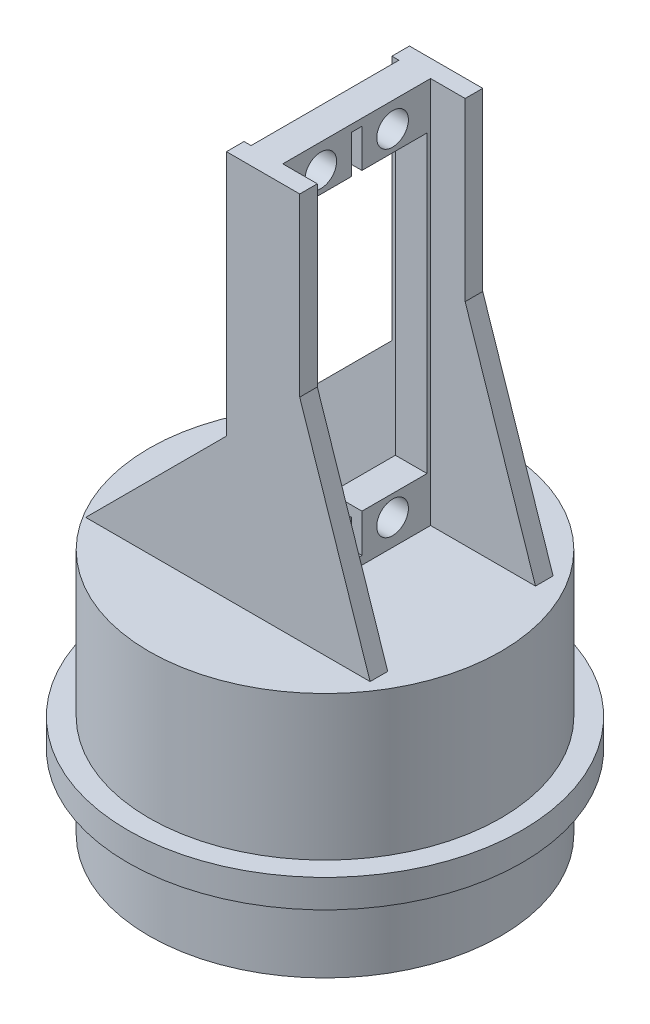
from build123d import *

# Parameters (mm, degrees)
SKETCH1_W           = 3
SKETCH1_H           = 4
SKETCH1_W_2         = 25
SKETCH1_H_2         = 35
SKETCH2_W           = 4.909608088
SKETCH2_H           = 2.5
SKETCH2_W_2         = 1
BOSS_EXTRUDE1_DEPTH = 55
CHAMFER1_SIZE       = 10
CHAMFER1_SIZE2      = 30
CHAMFER2_SIZE       = 20
SKETCH3_R           = 2.25
SKETCH3_W           = 20
SKETCH3_H           = 41.913950128
SKETCH3_W_2         = 1.5
SKETCH3_H_2         = 5.443024936
SKETCH3_W_3         = 1.501012669
CUT_EXTRUDE1_DEPTH  = 55
SKETCH5_W           = 15.682680147
SKETCH5_H           = 21
CUT_EXTRUDE2_DEPTH  = 36


with BuildPart() as part:
    # Sketch1 → Revolve1 (revolve)
    with BuildSketch(Plane.XY):
        with Locations((26.5, 12.5)):
            Rectangle(SKETCH1_W, SKETCH1_H)
        with Locations((12.5, 17.5)):
            Rectangle(SKETCH1_W_2, SKETCH1_H_2)
    revolve(axis=Axis((0, 35, 0), (0, -1, 0)))

    # Sketch2 → Boss-Extrude1 (add)
    with BuildSketch(Plane(origin=(0, 35, 0), x_dir=(1, 0, 0), z_dir=(0, 1, 0))):
        Polygon((4.5, 10.5), (4.5, 13), (0, 13), (0, 10.5), (0, -10.5), (0, -13), (4.5, -13), (4.5, -10.5), align=None)
        with Locations((6.954804044, 11.75)):
            Rectangle(SKETCH2_W, SKETCH2_H)
        with Locations((6.954804044, -11.75)):
            Rectangle(SKETCH2_W, SKETCH2_H)
        with Locations((-0.5, -11.75)):
            Rectangle(SKETCH2_W_2, SKETCH2_H)
        with Locations((-0.5, 11.75)):
            Rectangle(SKETCH2_W_2, SKETCH2_H)
    extrude(amount=BOSS_EXTRUDE1_DEPTH)

    # Chamfer1
    chamfer1_edges = [part.edges().sort_by_distance(p)[0] for p in [
        (9.409608088, 35, 11.75),
        (9.409608088, 35, -11.75),
    ]]
    chamfer1_side = [part.faces().sort_by_distance(p)[0] for p in [
        (-0.237473478, 35, 0),
    ]]
    chamfer(chamfer1_edges, length=CHAMFER1_SIZE, length2=CHAMFER1_SIZE2, reference=chamfer1_side[0])

    # Chamfer2
    chamfer2_edges = [part.edges().sort_by_distance(p)[0] for p in [
        (-1, 35, -11.75),
        (-1, 35, 11.75),
    ]]
    chamfer(chamfer2_edges, length=CHAMFER2_SIZE)

    # Sketch3 → Cut-Extrude1 (cut)
    with BuildSketch(Plane(origin=(4.5, 0, 0), x_dir=(0, 0, -1), z_dir=(1, 0, 0))):
        with Locations((-5.1, 86.5)):
            Circle(SKETCH3_R)
        with Locations((5.1, 86.5)):
            Circle(SKETCH3_R)
        with Locations((-5.1, 38.7)):
            Circle(SKETCH3_R)
        with Locations((5.1, 38.7)):
            Circle(SKETCH3_R)
        with Locations((0, 62.6)):
            Rectangle(SKETCH3_W, SKETCH3_H)
        with Locations((0, 86.278487532)):
            Rectangle(SKETCH3_W_2, SKETCH3_H_2)
        with Locations((-0.000506335, 38.921512468)):
            Rectangle(SKETCH3_W_3, SKETCH3_H_2)
    extrude(amount=-CUT_EXTRUDE1_DEPTH, mode=Mode.SUBTRACT)

    # Sketch5 → Cut-Extrude2 (cut, through all)
    with BuildSketch(Plane(origin=(0, 35, 0), x_dir=(1, 0, 0), z_dir=(0, 1, 0))):
        with Locations((-7.841340074, 0)):
            Rectangle(SKETCH5_W, SKETCH5_H)
    extrude(amount=-CUT_EXTRUDE2_DEPTH, mode=Mode.SUBTRACT)


solid = part.part
